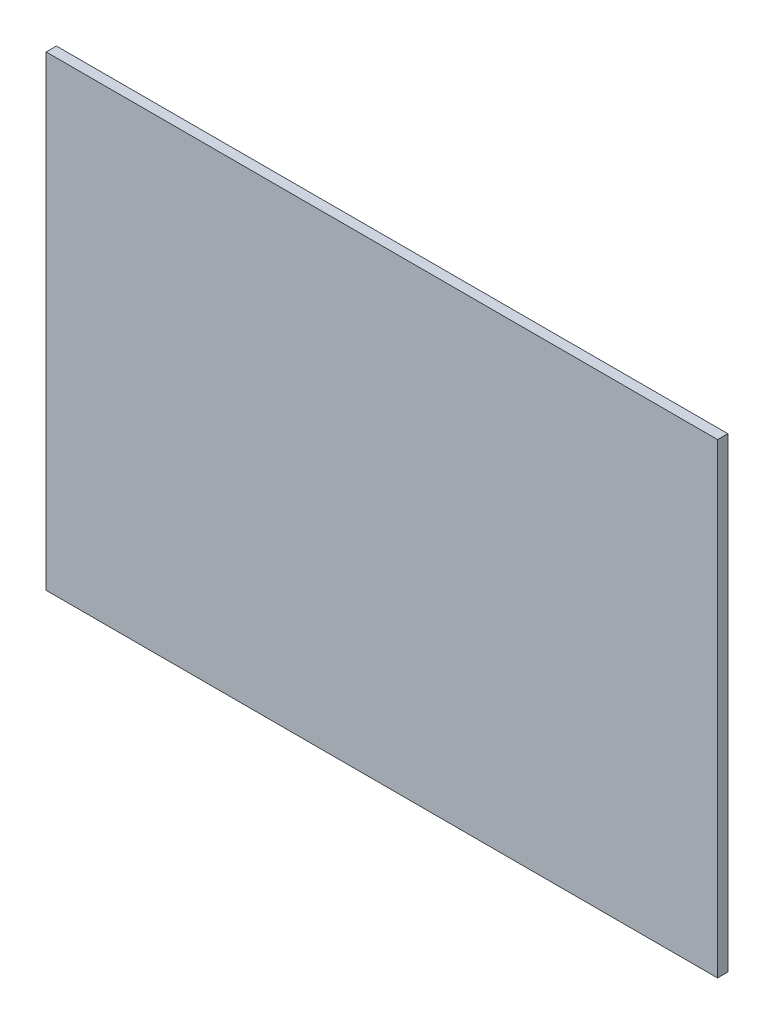
from build123d import *

# Parameters (mm, degrees)
SKETCH_1_W      = 72
SKETCH_1_H      = 50
EXTRUDE_1_DEPTH = 1.1


with BuildPart() as part:
    # 草图1 → 凸台-拉伸1 (new body)
    with BuildSketch(Plane.XY):
        with Locations((11, 0)):
            Rectangle(SKETCH_1_W, SKETCH_1_H)
    extrude(amount=EXTRUDE_1_DEPTH)


solid = part.part
